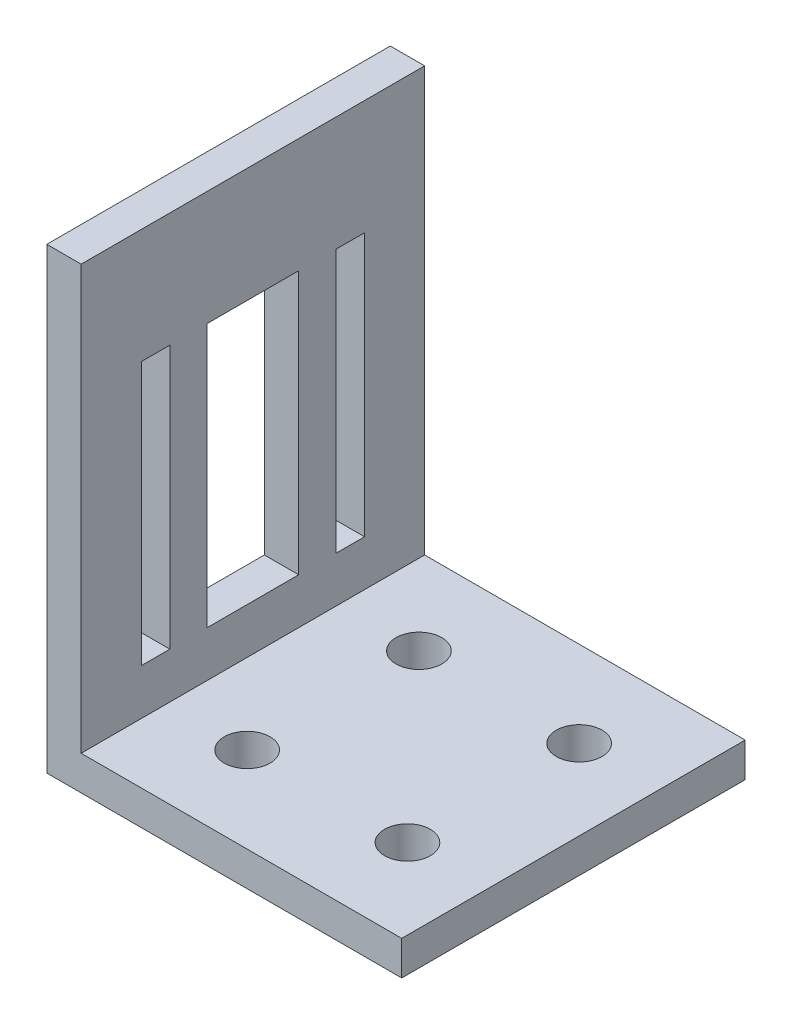
from build123d import *

# Parameters (mm, degrees)
BOSS_EXTRUDE1_DEPTH = 30
SKETCH3_R           = 2
CUT_EXTRUDE1_DEPTH  = 4
SKETCH5_W           = 2.5
SKETCH5_H           = 23
SKETCH5_W_2         = 8
CUT_EXTRUDE2_DEPTH  = 32


with BuildPart() as part:
    # Sketch2 → Boss-Extrude1 (new body)
    with BuildSketch(Plane.XY):
        Polygon((0, 0), (-31, 0), (-31, 40), (-28, 40), (-28, 3), (0, 3), align=None)
    extrude(amount=BOSS_EXTRUDE1_DEPTH)

    # Sketch3 → Cut-Extrude1 (cut, through all)
    with BuildSketch(Plane(origin=(0, 3, 0), x_dir=(1, 0, 0), z_dir=(0, 1, 0))):
        with Locations((-7, -22.5)):
            Circle(SKETCH3_R)
        with Locations((-21, -22.5)):
            Circle(SKETCH3_R)
        with Locations((-7, -7.5)):
            Circle(SKETCH3_R)
        with Locations((-21, -7.5)):
            Circle(SKETCH3_R)
    extrude(amount=-CUT_EXTRUDE1_DEPTH, mode=Mode.SUBTRACT)

    # Sketch5 → Cut-Extrude2 (cut, through all)
    with BuildSketch(Plane.ZY.offset(31)):
        with Locations((23.5, 18.5)):
            Rectangle(SKETCH5_W, SKETCH5_H)
        with Locations((15, 18.5)):
            Rectangle(SKETCH5_W_2, SKETCH5_H)
        with Locations((6.5, 18.5)):
            Rectangle(SKETCH5_W, SKETCH5_H)
    extrude(amount=-CUT_EXTRUDE2_DEPTH, mode=Mode.SUBTRACT)


solid = part.part
